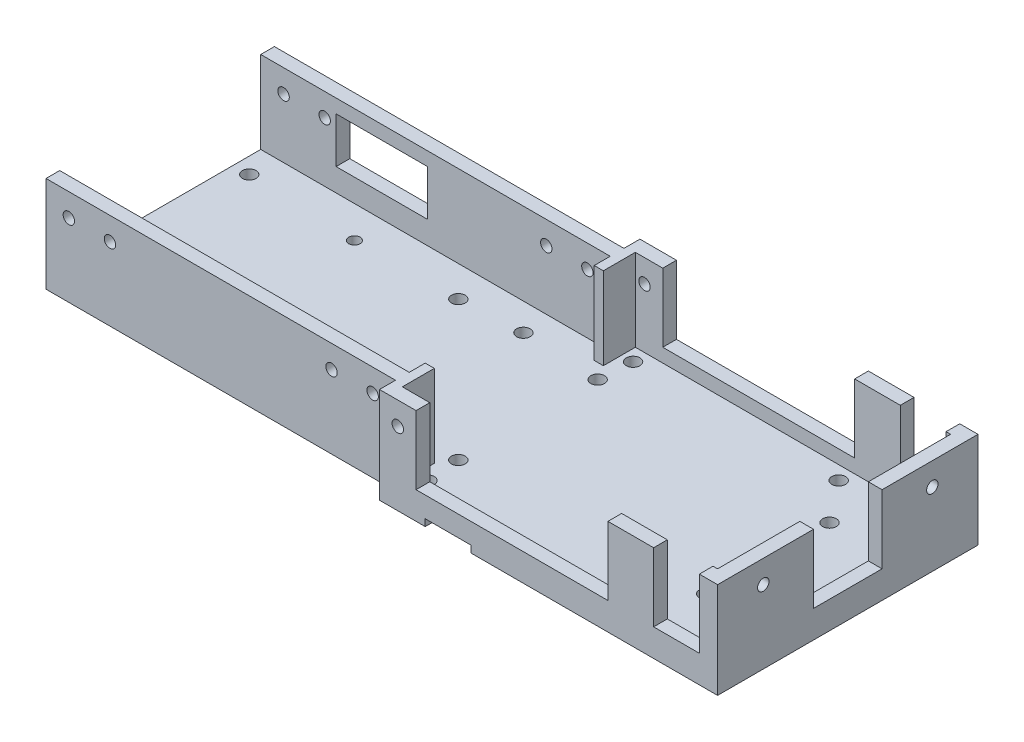
from build123d import *

# Parameters (mm, degrees)
SKETCH1_W           = 150.5
SKETCH1_H           = 50
BOSS_EXTRUDE1_DEPTH = 3
SKETCH2_R           = 1.5
SKETCH2_R_2         = 1.25
CUT_EXTRUDE1_DEPTH  = 4
SKETCH4_W           = 74
SKETCH4_H           = 3.5
BOSS_EXTRUDE2_DEPTH = 3
SKETCH5_R           = 1.5
CUT_EXTRUDE3_DEPTH  = 4
SKETCH6_W           = 76.5
SKETCH6_H           = 3
SKETCH6_W_2         = 8
SKETCH6_W_3         = 2
SKETCH6_H_2         = 7
SKETCH6_W_4         = 4
SKETCH6_W_5         = 3
SKETCH6_H_3         = 18
SKETCH6_W_6         = 10
BOSS_EXTRUDE3_DEPTH = 18
SKETCH8_W           = 10
SKETCH8_H           = 3
SKETCH8_H_2         = 2
SKETCH8_W_2         = 42
SKETCH8_W_3         = 3
SKETCH8_H_3         = 15
BOSS_EXTRUDE4_DEPTH = 3
CUT_EXTRUDE4_REACH  = 55.5
SKETCH9_W           = 20
SKETCH9_H           = 10
CUT_EXTRUDE5_REACH  = 152.5
SKETCH10_R          = 1.25
SKETCH11_R          = 1.25
CUT_EXTRUDE6_DEPTH  = 54.5
SKETCH12_R          = 1.25
CUT_EXTRUDE7_DEPTH  = 58
SKETCH13_W          = 10
SKETCH13_H          = 1.5
CUT_EXTRUDE8_DEPTH  = 1.5


with BuildPart() as part:
    # Sketch1 → Boss-Extrude1 (new body)
    with BuildSketch(Plane(origin=(0, 0, 0), x_dir=(1, 0, 0), z_dir=(0, 1, 0))):
        with Locations((-39.87052506, -3.090692124)):
            Rectangle(SKETCH1_W, SKETCH1_H)
    extrude(amount=BOSS_EXTRUDE1_DEPTH)

    # Sketch2 → Cut-Extrude1 (cut, through all)
    with BuildSketch(Plane(origin=(0, 3, 0), x_dir=(1, 0, 0), z_dir=(0, 1, 0))):
        with Locations((-65.12052506, 12.159307876)):
            Circle(SKETCH2_R)
        with Locations((-65.12052506, -18.340692124)):
            Circle(SKETCH2_R)
        with Locations((-34.62052506, -18.340692124)):
            Circle(SKETCH2_R)
        with Locations((-34.62052506, 12.159307876)):
            Circle(SKETCH2_R)
        with Locations((17.87947494, -16.590692124)):
            Circle(SKETCH2_R)
        with Locations((17.87947494, 10.409307876)):
            Circle(SKETCH2_R)
        with Locations((-111.62052506, -19.090692124)):
            Circle(SKETCH2_R)
        with Locations((-111.62052506, 12.909307876)):
            Circle(SKETCH2_R)
        with Locations((-87.62052506, 11.909307876)):
            Circle(SKETCH2_R_2)
        with Locations((-87.62052506, -18.090692124)):
            Circle(SKETCH2_R_2)
        with Locations((-51.62052506, 12.909307876)):
            Circle(SKETCH2_R)
        with Locations((-51.62052506, -19.090692124)):
            Circle(SKETCH2_R)
    extrude(amount=-CUT_EXTRUDE1_DEPTH, mode=Mode.SUBTRACT)

    # Sketch4 → Boss-Extrude2 (add)
    with BuildSketch(Plane(origin=(0, 3, 0), x_dir=(1, 0, 0), z_dir=(0, 1, 0))):
        with Locations((-1.62052506, -29.840692124)):
            Rectangle(SKETCH4_W, SKETCH4_H)
        with Locations((-1.62052506, 23.659307876)):
            Rectangle(SKETCH4_W, SKETCH4_H)
    extrude(amount=-BOSS_EXTRUDE2_DEPTH)

    # Sketch5 → Cut-Extrude3 (cut, through all)
    with BuildSketch(Plane(origin=(0, 3, 0), x_dir=(1, 0, 0), z_dir=(0, 1, 0))):
        with Locations((-34.12052506, 19.409307876)):
            Circle(SKETCH5_R)
        with Locations((-34.12052506, -25.590692124)):
            Circle(SKETCH5_R)
        with Locations((10.87947494, 19.409307876)):
            Circle(SKETCH5_R)
        with Locations((10.87947494, -25.590692124)):
            Circle(SKETCH5_R)
    extrude(amount=-CUT_EXTRUDE3_DEPTH, mode=Mode.SUBTRACT)

    # Sketch6 → Boss-Extrude3 (add)
    with BuildSketch(Plane(origin=(0, 3, 0), x_dir=(1, 0, 0), z_dir=(0, 1, 0))):
        Polygon((35.37947494, 25.409307876), (31.37947494, 25.409307876), (31.37947494, 22.409307876), (32.37947494, 22.409307876), (35.37947494, 22.409307876), align=None)
        with Locations((-76.87052506, -26.590692124)):
            Rectangle(SKETCH6_W, SKETCH6_H)
        with Locations((-76.87052506, 20.409307876)):
            Rectangle(SKETCH6_W, SKETCH6_H)
        with Locations((-34.62052506, 23.909307876)):
            Rectangle(SKETCH6_W_2, SKETCH6_H)
        with Locations((-34.62052506, -30.090692124)):
            Rectangle(SKETCH6_W_2, SKETCH6_H)
        with Locations((-37.62052506, -25.090692124)):
            Rectangle(SKETCH6_W_3, SKETCH6_H_2)
        with Locations((-37.62052506, 18.909307876)):
            Rectangle(SKETCH6_W_3, SKETCH6_H_2)
        with Locations((33.37947494, -30.090692124)):
            Rectangle(SKETCH6_W_4, SKETCH6_H)
        with Locations((33.87947494, -19.590692124)):
            Rectangle(SKETCH6_W_5, SKETCH6_H_3)
        with Locations((33.87947494, 13.409307876)):
            Rectangle(SKETCH6_W_5, SKETCH6_H_3)
        with Locations((16.37947494, -30.090692124)):
            Rectangle(SKETCH6_W_6, SKETCH6_H)
        with Locations((16.37947494, 23.909307876)):
            Rectangle(SKETCH6_W_6, SKETCH6_H)
    extrude(amount=BOSS_EXTRUDE3_DEPTH)

    # Sketch8 → Boss-Extrude4 (add)
    with BuildSketch(Plane(origin=(0, 3, 0), x_dir=(1, 0, 0), z_dir=(0, 1, 0))):
        with Locations((26.37947494, -30.090692124)):
            Rectangle(SKETCH8_W, SKETCH8_H)
        with Locations((26.37947494, 24.409307876)):
            Rectangle(SKETCH8_W, SKETCH8_H_2)
        with Locations((-9.62052506, 23.909307876)):
            Rectangle(SKETCH8_W_2, SKETCH8_H)
        with Locations((-9.62052506, -30.090692124)):
            Rectangle(SKETCH8_W_2, SKETCH8_H)
        with Locations((33.87947494, -3.090692124)):
            Rectangle(SKETCH8_W_3, SKETCH8_H_3)
    extrude(amount=BOSS_EXTRUDE4_DEPTH)

    # Sketch9 → Cut-Extrude4 (cut, up to next)
    with BuildSketch(Plane(origin=(0, 0, -21.909307876), x_dir=(-1, 0, 0), z_dir=(0, 0, -1)), mode=Mode.PRIVATE) as cut_extrude4_sk1:
        with Locations((88.62052506, 13)):
            Rectangle(SKETCH9_W, SKETCH9_H)
    cut_extrude4_tool1 = extrude(cut_extrude4_sk1.sketch, amount=-CUT_EXTRUDE4_REACH, mode=Mode.PRIVATE) & part.part
    add(cut_extrude4_tool1.solids().sort_by_distance((-88.620525, 13, -21.909308))[0], mode=Mode.SUBTRACT)

    # Sketch10 → Cut-Extrude5 (cut, up to next)
    with BuildSketch(Plane(origin=(35.37947494, 0, 0), x_dir=(0, 0, -1), z_dir=(1, 0, 0)), mode=Mode.PRIVATE) as cut_extrude5_sk1:
        with Locations((-21.590692124, 16)):
            Circle(SKETCH10_R)
    cut_extrude5_tool1 = extrude(cut_extrude5_sk1.sketch, amount=-CUT_EXTRUDE5_REACH, mode=Mode.PRIVATE) & part.part
    add(cut_extrude5_tool1.solids().sort_by_distance((35.379475, 16, 21.590692))[0], mode=Mode.SUBTRACT)
    # Sketch10 → Cut-Extrude5 (cut, up to next)
    with BuildSketch(Plane(origin=(35.37947494, 0, 0), x_dir=(0, 0, -1), z_dir=(1, 0, 0)), mode=Mode.PRIVATE) as cut_extrude5_sk2:
        with Locations((15.409307876, 16)):
            Circle(SKETCH10_R)
    cut_extrude5_tool2 = extrude(cut_extrude5_sk2.sketch, amount=-CUT_EXTRUDE5_REACH, mode=Mode.PRIVATE) & part.part
    add(cut_extrude5_tool2.solids().sort_by_distance((35.379475, 16, -15.409308))[0], mode=Mode.SUBTRACT)

    # Sketch11 → Cut-Extrude6 (cut, through all)
    with BuildSketch(Plane(origin=(0, 0, -21.909307876), x_dir=(-1, 0, 0), z_dir=(0, 0, -1))):
        with Locations((43.62052506, 16)):
            Circle(SKETCH11_R)
        with Locations((110.12052506, 16)):
            Circle(SKETCH11_R)
        with Locations((52.62052506, 16)):
            Circle(SKETCH11_R)
        with Locations((101.12052506, 16)):
            Circle(SKETCH11_R)
    extrude(amount=-CUT_EXTRUDE6_DEPTH, mode=Mode.SUBTRACT)

    # Sketch12 → Cut-Extrude7 (cut, through all)
    with BuildSketch(Plane(origin=(0, 0, -25.409307876), x_dir=(-1, 0, 0), z_dir=(0, 0, -1))):
        with Locations((34.62052506, 16)):
            Circle(SKETCH12_R)
    extrude(amount=-CUT_EXTRUDE7_DEPTH, mode=Mode.SUBTRACT)

    # Sketch13 → Cut-Extrude8 (cut)
    with BuildSketch(Plane(origin=(0, 0, 0), x_dir=(-1, 0, 0), z_dir=(0, -1, 0))):
        with Locations((23.62052506, -30.840692124)):
            Rectangle(SKETCH13_W, SKETCH13_H)
        with Locations((23.62052506, 24.659307876)):
            Rectangle(SKETCH13_W, SKETCH13_H)
    extrude(amount=-CUT_EXTRUDE8_DEPTH, mode=Mode.SUBTRACT)


solid = part.part
